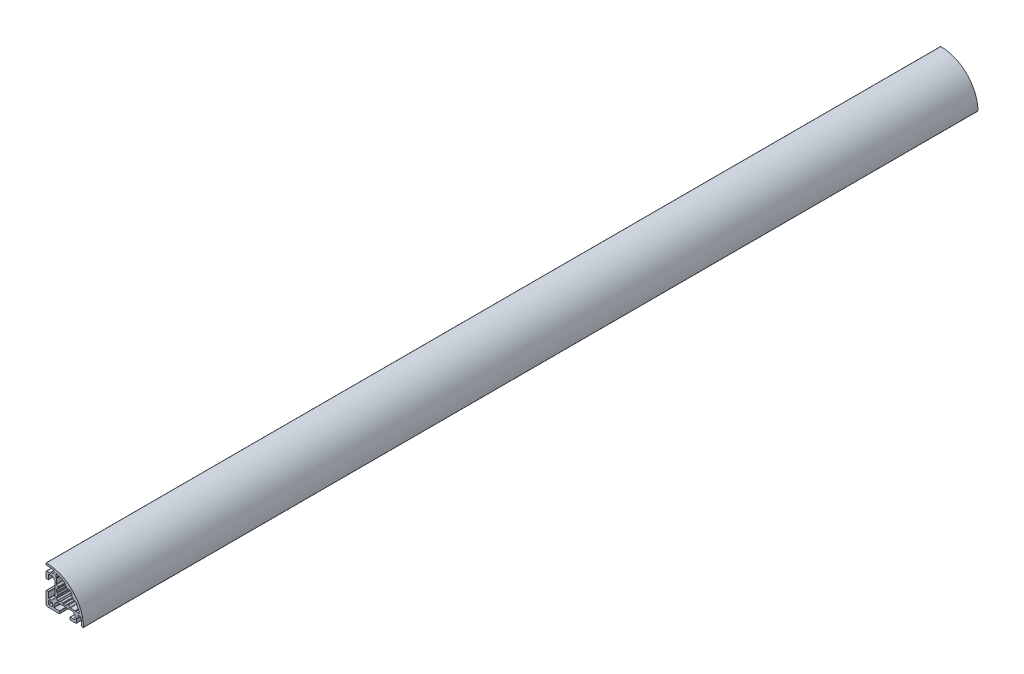
from build123d import *

# Parameters (mm, degrees)
RESSALTO_EXTRUS_O1_DEPTH = 715


with BuildPart() as part:
    # Esboço1 → Ressalto-extrusão1 (new body)
    with BuildSketch(Plane(origin=(0, 0, 0), x_dir=(-1, 0, 0), z_dir=(0, 0, -1))):
        with BuildLine():
            Line((7.988219541, 6.432338758), (8.704487641, 7.072382973))
            Line((8.704487641, 7.072382973), (8.728293149, 7.496120151))
            Line((8.728293149, 7.496120151), (9.151562381, 7.472340932))
            Line((9.151562381, 7.472340932), (9.867827891, 8.112367217))
            ThreePointArc((9.867827891, 8.112367217), (9.965155948, 8.177397462), (10.079961344, 8.200231741))
            Line((10.079961344, 8.200231741), (12.700062746, 8.200189288))
            ThreePointArc((12.700062746, 8.200189288), (12.912193499, 8.112317744), (13.000057885, 7.900184026))
            Line((13.000057885, 7.900184026), (12.999995614, 4.350227048))
            ThreePointArc((12.999995614, 4.350227048), (13.087860246, 4.138093085), (13.299991447, 4.050221785))
            Line((13.299991447, 4.050221785), (14.699990096, 4.050202343))
            ThreePointArc((14.699990096, 4.050202343), (14.912124824, 4.138068835), (14.999994262, 4.350202343))
            Line((14.999994262, 4.350202343), (14.999994262, 8.899908545))
            ThreePointArc((14.999994262, 8.899908545), (14.853547653, 9.253461936), (14.499994262, 9.399908545))
            Line((14.499994262, 9.399908545), (11.299984015, 9.399908545))
            ThreePointArc((11.299984015, 9.399908545), (11.087851981, 9.487776511), (10.999984015, 9.699908545))
            Line((10.999984015, 9.699908545), (10.999984015, 10.199939564))
            ThreePointArc((10.999984015, 10.199939564), (10.91211588, 10.412072007), (10.699983437, 10.499940142))
            Line((10.699983437, 10.499940142), (8.799996289, 10.499940142))
            ThreePointArc((8.799996289, 10.499940142), (8.587864255, 10.587808108), (8.499996289, 10.799940142))
            Line((8.499996289, 10.799940142), (8.499996289, 12.509984621))
            ThreePointArc((8.499996289, 12.509984621), (8.565702422, 12.697351597), (8.734038846, 12.802644177))
            ThreePointArc((8.734038846, 12.802644177), (11.700188414, 13.308311468), (14.703119279, 13.498440079))
            ThreePointArc((14.703119279, 13.498440079), (14.913228295, 13.587399521), (14.999994262, 13.798423803))
            Line((14.999994262, 13.798423803), (14.999994262, 14.698471418))
            ThreePointArc((14.999994262, 14.698471418), (14.911052198, 14.911672141), (14.696963943, 14.998456113))
            ThreePointArc((14.696963943, 14.998456113), (-6.213201777, 6.213195799), (-14.998473404, -14.696965168))
            ThreePointArc((-14.998473404, -14.696965168), (-14.91168949, -14.911053528), (-14.69848871, -14.99999565))
            Line((-14.69848871, -14.99999565), (-13.798441347, -14.99999565))
            ThreePointArc((-13.798441347, -14.99999565), (-13.587416943, -14.913229667), (-13.498457365, -14.70312058))
            ThreePointArc((-13.498457365, -14.70312058), (-13.308326814, -11.700187782), (-12.802657176, -8.734036533))
            ThreePointArc((-12.802657176, -8.734036533), (-12.69756035, -8.565856959), (-12.510499232, -8.499994604))
            Line((-12.510499232, -8.499994604), (-10.800466095, -8.49997976))
            ThreePointArc((-10.800466095, -8.49997976), (-10.588332377, -8.587846805), (-10.500463491, -8.79997976))
            Line((-10.500463491, -8.79997976), (-10.500463491, -10.699963204))
            ThreePointArc((-10.500463491, -10.699963204), (-10.412595525, -10.912095238), (-10.200463491, -10.999963204))
            Line((-10.200463491, -10.999963204), (-9.700412566, -10.999963204))
            ThreePointArc((-9.700412566, -10.999963204), (-9.488279549, -11.087832151), (-9.400412566, -11.299965981))
            Line((-9.400412566, -11.299965981), (-9.400442195, -14.49999102))
            ThreePointArc((-9.400442195, -14.49999102), (-9.253997222, -14.853547404), (-8.900442195, -14.99999565))
            Line((-8.900442195, -14.99999565), (-4.350452582, -14.99999565))
            ThreePointArc((-4.350452582, -14.99999565), (-4.138321038, -14.912128175), (-4.050452582, -14.699997039))
            Line((-4.050452582, -14.699997039), (-4.0504461, -13.299966156))
            ThreePointArc((-4.0504461, -13.299966156), (-4.138313069, -13.087833729), (-4.350444671, -12.999964767))
            Line((-4.350444671, -12.999964767), (-7.90045314, -12.999947852))
            ThreePointArc((-7.90045314, -12.999947852), (-8.112584733, -12.912078899), (-8.200451711, -12.699946488))
            Line((-8.200451711, -12.699946488), (-8.2004398, -10.079879081))
            ThreePointArc((-8.2004398, -10.079879081), (-8.177603139, -9.965074158), (-8.112570875, -9.867747451))
            Line((-8.112570875, -9.867747451), (-7.472516642, -9.151499458))
            Line((-7.472516642, -9.151499458), (-7.496307785, -8.728000464))
            Line((-7.496307785, -8.728000464), (-7.07269541, -8.704202951))
            Line((-7.07269541, -8.704202951), (-6.432641175, -7.987954957))
            ThreePointArc((-6.432641175, -7.987954957), (-6.33531386, -7.922923563), (-6.220508707, -7.900087947))
            Line((-6.220508707, -7.900087947), (6.219693645, -7.900145542))
            ThreePointArc((6.219693645, -7.900145542), (6.33449792, -7.922981945), (6.431824279, -7.988013496))
            Line((6.431824279, -7.988013496), (8.71172379, -10.467916072))
            ThreePointArc((8.71172379, -10.467916072), (8.776761952, -10.565245573), (8.799600807, -10.680055769))
            Line((8.799600807, -10.680055769), (8.79961016, -12.700073336))
            ThreePointArc((8.79961016, -12.700073336), (8.711742982, -12.912205971), (8.499611001, -13.000074725))
            Line((8.499611001, -13.000074725), (4.349602, -13.000086362))
            ThreePointArc((4.349602, -13.000086362), (4.137471001, -13.087954134), (4.049602841, -13.300084973))
            Line((4.049602841, -13.300084973), (4.04959636, -14.699994261))
            ThreePointArc((4.04959636, -14.699994261), (4.137463835, -14.912127193), (4.349596361, -14.99999565))
            Line((4.349596361, -14.99999565), (13.499994262, -14.99999565))
            ThreePointArc((13.499994262, -14.99999565), (14.560654434, -14.560655822), (14.999994262, -13.49999565))
            Line((14.999994262, -13.49999565), (14.999994262, -4.349951929))
            ThreePointArc((14.999994262, -4.349951929), (14.912126297, -4.137819895), (14.699994262, -4.049951929))
            Line((14.699994262, -4.049951929), (13.299941692, -4.049951929))
            ThreePointArc((13.299941692, -4.049951929), (13.087809804, -4.137819748), (12.999941692, -4.349951515))
            Line((12.999941692, -4.349951515), (12.999935957, -8.499908737))
            ThreePointArc((12.999935957, -8.499908737), (12.9120676, -8.712040749), (12.699935263, -8.799908323))
            Line((12.699935263, -8.799908323), (10.679833904, -8.799903647))
            ThreePointArc((10.679833904, -8.799903647), (10.565028929, -8.777067242), (10.467702076, -8.712035194))
            Line((10.467702076, -8.712035194), (7.987808147, -6.432129961))
            ThreePointArc((7.987808147, -6.432129961), (7.922994822, -6.334753653), (7.900348133, -6.219992858))
            Line((7.900348133, -6.219992858), (7.900348133, 6.220203281))
            ThreePointArc((7.900348133, 6.220203281), (7.923185205, 6.33501056), (7.988219541, 6.432338758))
        make_face()
        with BuildLine():
            Line((12.699997649, -12.999995366), (10.299997649, -12.999995366))
            ThreePointArc((10.299997649, -12.999995366), (10.087865615, -12.9121274), (9.999997649, -12.699995366))
            Line((9.999997649, -12.699995366), (9.999997649, -10.299995366))
            ThreePointArc((9.999997649, -10.299995366), (10.087865615, -10.087863332), (10.299997649, -9.999995366))
            Line((10.299997649, -9.999995366), (12.699997649, -9.999995366))
            ThreePointArc((12.699997649, -9.999995366), (12.912129683, -10.087863332), (12.999997649, -10.299995366))
            Line((12.999997649, -10.299995366), (12.999997649, -12.699995366))
            ThreePointArc((12.999997649, -12.699995366), (12.912129683, -12.9121274), (12.699997649, -12.999995366))
        make_face(mode=Mode.SUBTRACT)
        with BuildLine():
            Line((-0.949997542, 6.699991608), (-0.300006198, 6.699991608))
            ThreePointArc((-0.300006198, 6.699991608), (-0.087874164, 6.787859574), (-6.198e-06, 6.999991608))
            Line((-6.198e-06, 6.999991608), (-6.198e-06, 8.47764802))
            ThreePointArc((-6.198e-06, 8.47764802), (0.037542168, 8.622972279), (0.140788069, 8.731918614))
            ThreePointArc((0.140788069, 8.731918614), (3.280244614, 10.429262729), (6.61010457, 11.713473425))
            ThreePointArc((6.61010457, 11.713473425), (6.877524397, 11.669091748), (6.999996226, 11.427257614))
            Line((6.999996226, 11.427257614), (6.999996226, 8.679894243))
            ThreePointArc((6.999996226, 8.679894243), (6.977160088, 8.565089218), (6.912128268, 8.467762216))
            Line((6.912128268, 8.467762216), (6.787851146, 8.343485086))
            ThreePointArc((6.787851146, 8.343485086), (6.722819326, 8.246158084), (6.699983188, 8.131353059))
            Line((6.699983188, 8.131353059), (6.699983188, 4.349373523))
            ThreePointArc((6.699983188, 4.349373523), (6.677147048, 4.234568493), (6.612115222, 4.137241489))
            Line((6.612115222, 4.137241489), (5.487142739, 3.012269005))
            ThreePointArc((5.487142739, 3.012269005), (5.403317864, 2.849223708), (5.430017697, 2.667847035))
            ThreePointArc((5.430017697, 2.667847035), (5.679815237, 2.083794343), (5.866996881, 1.47676931))
            ThreePointArc((5.866996881, 1.47676931), (5.973488711, 1.313387662), (6.157922346, 1.249997541))
            Line((6.157922346, 1.249997541), (6.399983188, 1.249997541))
            ThreePointArc((6.399983188, 1.249997541), (6.612115222, 1.162129575), (6.699983188, 0.949997541))
            Line((6.699983188, 0.949997541), (6.699983188, -0.949997542))
            ThreePointArc((6.699983188, -0.949997542), (6.612115222, -1.162129576), (6.399983188, -1.249997542))
            Line((6.399983188, -1.249997542), (6.157922346, -1.249997542))
            ThreePointArc((6.157922346, -1.249997542), (5.973488711, -1.313387663), (5.866996881, -1.476769311))
            ThreePointArc((5.866996881, -1.476769311), (5.679815237, -2.083794344), (5.430017697, -2.667847036))
            ThreePointArc((5.430017697, -2.667847036), (5.403317864, -2.849223709), (5.487142739, -3.012269006))
            Line((5.487142739, -3.012269006), (6.612115222, -4.13724149))
            ThreePointArc((6.612115222, -4.13724149), (6.677147048, -4.234568494), (6.699983188, -4.349373524))
            Line((6.699983188, -4.349373524), (6.699983188, -5.439573887))
            ThreePointArc((6.699983188, -5.439573887), (6.677147048, -5.554378917), (6.612115222, -5.651705921))
            Line((6.612115222, -5.651705921), (5.651680826, -6.612140317))
            ThreePointArc((5.651680826, -6.612140317), (5.554353822, -6.677172143), (5.439548792, -6.700008283))
            Line((5.439548792, -6.700008283), (4.349398617, -6.700008283))
            ThreePointArc((4.349398617, -6.700008283), (4.234593588, -6.677172143), (4.137266583, -6.612140317))
            Line((4.137266583, -6.612140317), (3.012269005, -5.48714274))
            ThreePointArc((3.012269005, -5.48714274), (2.849223708, -5.403317864), (2.667847035, -5.430017698))
            ThreePointArc((2.667847035, -5.430017698), (2.083794343, -5.679815238), (1.47676931, -5.866996882))
            ThreePointArc((1.47676931, -5.866996882), (1.313387662, -5.973488713), (1.24999754, -6.157922347))
            Line((1.24999754, -6.157922347), (1.24999754, -6.400008283))
            ThreePointArc((1.24999754, -6.400008283), (1.162129575, -6.612140317), (0.94999754, -6.700008283))
            Line((0.94999754, -6.700008283), (-0.949997542, -6.700008283))
            ThreePointArc((-0.949997542, -6.700008283), (-1.162129576, -6.612140317), (-1.249997542, -6.400008283))
            Line((-1.249997542, -6.400008283), (-1.249997542, -6.157922347))
            ThreePointArc((-1.249997542, -6.157922347), (-1.313387663, -5.973488713), (-1.476769311, -5.866996882))
            ThreePointArc((-1.476769311, -5.866996882), (-2.083794344, -5.679815238), (-2.667847036, -5.430017698))
            ThreePointArc((-2.667847036, -5.430017698), (-2.849223709, -5.403317865), (-3.012269006, -5.48714274))
            Line((-3.012269006, -5.48714274), (-4.137266583, -6.612140317))
            ThreePointArc((-4.137266583, -6.612140317), (-4.234593588, -6.677172143), (-4.349398618, -6.700008283))
            Line((-4.349398618, -6.700008283), (-8.131377093, -6.700008283))
            ThreePointArc((-8.131377093, -6.700008283), (-8.246182127, -6.722844425), (-8.343509135, -6.787876256))
            Line((-8.343509135, -6.787876256), (-8.467778577, -6.912145707))
            ThreePointArc((-8.467778577, -6.912145707), (-8.565105584, -6.977177538), (-8.679910619, -7.00001368))
            Line((-8.679910619, -7.00001368), (-11.427275069, -7.00001368))
            ThreePointArc((-11.427275069, -7.00001368), (-11.669109203, -6.877541852), (-11.713490879, -6.610122025))
            ThreePointArc((-11.713490879, -6.610122025), (-10.429280184, -3.280262068), (-8.731936068, -0.140805524))
            ThreePointArc((-8.731936068, -0.140805524), (-8.622989733, -0.037559623), (-8.477665474, -1.1256e-05))
            Line((-8.477665474, -1.1256e-05), (-7.000004228, -1.1256e-05))
            ThreePointArc((-7.000004228, -1.1256e-05), (-6.787872194, 0.08785671), (-6.700004228, 0.299988744))
            Line((-6.700004228, 0.299988744), (-6.700004228, 0.94999754))
            ThreePointArc((-6.700004228, 0.94999754), (-6.612136263, 1.162129574), (-6.400004228, 1.24999754))
            Line((-6.400004228, 1.24999754), (-6.157922347, 1.24999754))
            ThreePointArc((-6.157922347, 1.24999754), (-5.973488713, 1.313387661), (-5.866996882, 1.476769309))
            ThreePointArc((-5.866996882, 1.476769309), (-5.679815238, 2.083794343), (-5.430017698, 2.667847035))
            ThreePointArc((-5.430017698, 2.667847035), (-5.403317865, 2.849223708), (-5.48714274, 3.012269005))
            Line((-5.48714274, 3.012269005), (-5.797444779, 3.322571045))
            ThreePointArc((-5.797444779, 3.322571045), (-5.885209902, 3.526848471), (-5.808258232, 3.735439996))
            ThreePointArc((-5.808258232, 3.735439996), (-4.798993375, 4.798993588), (-3.735438882, 5.808257496))
            ThreePointArc((-3.735438882, 5.808257496), (-3.526847423, 5.885208983), (-3.322570131, 5.797443864))
            Line((-3.322570131, 5.797443864), (-3.012269006, 5.487142739))
            ThreePointArc((-3.012269006, 5.487142739), (-2.849223709, 5.403317864), (-2.667847036, 5.430017697))
            ThreePointArc((-2.667847036, 5.430017697), (-2.083794344, 5.679815237), (-1.476769311, 5.866996881))
            ThreePointArc((-1.476769311, 5.866996881), (-1.313387663, 5.973488711), (-1.249997542, 6.157922346))
            Line((-1.249997542, 6.157922346), (-1.249997542, 6.399991608))
            ThreePointArc((-1.249997542, 6.399991608), (-1.162129576, 6.612123643), (-0.949997542, 6.699991608))
        make_face(mode=Mode.SUBTRACT)
    extrude(amount=-RESSALTO_EXTRUS_O1_DEPTH)


solid = part.part
